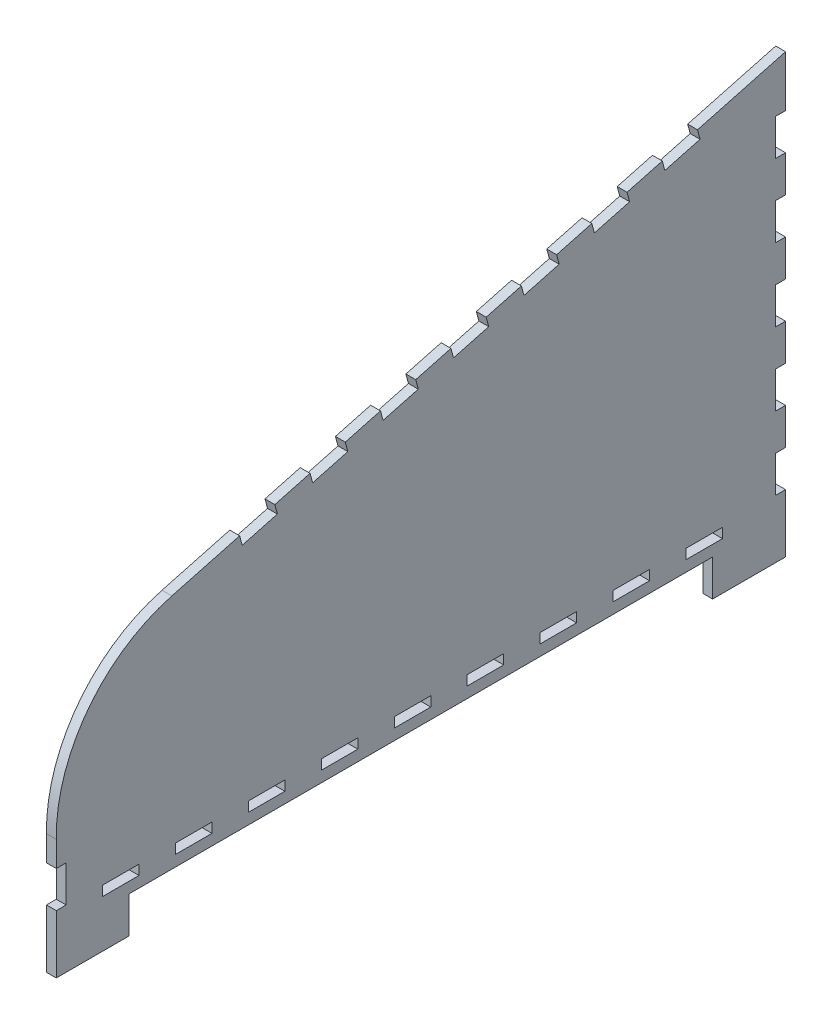
from build123d import *

# Parameters (mm, degrees)
SKETCH1_W           = 10
SKETCH1_H           = 2.7
BOSS_EXTRUDE1_DEPTH = 2.7


with BuildPart() as part:
    # Sketch1 → Boss-Extrude1 (new body)
    with BuildSketch(Plane(origin=(0, 0, 0), x_dir=(0, 0, -1), z_dir=(1, 0, 0))):
        with BuildLine():
            Line((-100, -44), (-100, -60))
            Line((-100, -60), (-80, -60))
            Line((-80, -60), (-80, -50))
            Line((-80, -50), (80, -50))
            Line((80, -50), (80, -60))
            Line((80, -60), (100, -60))
            Line((100, -60), (100, -44))
            Line((100, -44), (97.3, -44))
            Line((97.3, -44), (97.3, -34))
            Line((97.3, -34), (100, -34))
            Line((100, -34), (100, -24))
            Line((100, -24), (97.3, -24))
            Line((97.3, -24), (97.3, -14))
            Line((97.3, -14), (100, -14))
            Line((100, -14), (100, -4))
            Line((100, -4), (97.3, -4))
            Line((97.3, -4), (97.3, 6))
            Line((97.3, 6), (100, 6))
            Line((100, 6), (100, 16))
            Line((100, 16), (97.3, 16))
            Line((97.3, 16), (97.3, 26))
            Line((97.3, 26), (100, 26))
            Line((100, 26), (100, 36))
            Line((100, 36), (97.3, 36))
            Line((97.3, 36), (97.3, 46))
            Line((97.3, 46), (100, 46))
            Line((100, 46), (100, 60))
            Line((100, 60), (75.851854343, 53.529523872))
            Line((75.851854343, 53.529523872), (76.550665765, 50.921524141))
            Line((76.550665765, 50.921524141), (66.891407502, 48.33333369))
            Line((66.891407502, 48.33333369), (66.19259608, 50.941333421))
            Line((66.19259608, 50.941333421), (56.533337817, 48.35314297))
            Line((56.533337817, 48.35314297), (57.232149239, 45.745143239))
            Line((57.232149239, 45.745143239), (47.572890976, 43.156952788))
            Line((47.572890976, 43.156952788), (46.874079554, 45.764952519))
            Line((46.874079554, 45.764952519), (37.214821291, 43.176762068))
            Line((37.214821291, 43.176762068), (37.913632713, 40.568762337))
            Line((37.913632713, 40.568762337), (28.25437445, 37.980571886))
            Line((28.25437445, 37.980571886), (27.555563028, 40.588571617))
            Line((27.555563028, 40.588571617), (17.896304765, 38.000381166))
            Line((17.896304765, 38.000381166), (18.595116187, 35.392381435))
            Line((18.595116187, 35.392381435), (8.935857924, 32.804190984))
            Line((8.935857924, 32.804190984), (8.237046503, 35.412190715))
            Line((8.237046503, 35.412190715), (-1.42221176, 32.824000264))
            Line((-1.42221176, 32.824000264), (-0.723400339, 30.216000533))
            Line((-0.723400339, 30.216000533), (-10.382658601, 27.627810082))
            Line((-10.382658601, 27.627810082), (-11.081470023, 30.235809813))
            Line((-11.081470023, 30.235809813), (-20.740728286, 27.647619362))
            Line((-20.740728286, 27.647619362), (-20.041916864, 25.039619631))
            Line((-20.041916864, 25.039619631), (-29.701175127, 22.45142918))
            Line((-29.701175127, 22.45142918), (-30.399986549, 25.059428911))
            Line((-30.399986549, 25.059428911), (-40.059244812, 22.47123846))
            Line((-40.059244812, 22.47123846), (-39.36043339, 19.863238729))
            Line((-39.36043339, 19.863238729), (-49.019691653, 17.275048278))
            Line((-49.019691653, 17.275048278), (-49.718503075, 19.883048009))
            Line((-49.718503075, 19.883048009), (-68.302221487, 14.903555668))
            ThreePointArc((-68.302221487, 14.903555668), (-91.366544651, -0.636913735), (-100, -27.074247963))
            Line((-100, -27.074247963), (-100, -34))
            Line((-100, -34), (-97.3, -34))
            Line((-97.3, -34), (-97.3, -44))
            Line((-97.3, -44), (-100, -44))
        make_face()
        with Locations((-82.3, -45.65)):
            Rectangle(SKETCH1_W, SKETCH1_H, mode=Mode.SUBTRACT)
        with Locations((-62.3, -45.65)):
            Rectangle(SKETCH1_W, SKETCH1_H, mode=Mode.SUBTRACT)
        with Locations((-42.3, -45.65)):
            Rectangle(SKETCH1_W, SKETCH1_H, mode=Mode.SUBTRACT)
        with Locations((-22.3, -45.65)):
            Rectangle(SKETCH1_W, SKETCH1_H, mode=Mode.SUBTRACT)
        with Locations((-2.3, -45.65)):
            Rectangle(SKETCH1_W, SKETCH1_H, mode=Mode.SUBTRACT)
        with Locations((17.7, -45.65)):
            Rectangle(SKETCH1_W, SKETCH1_H, mode=Mode.SUBTRACT)
        with Locations((37.7, -45.65)):
            Rectangle(SKETCH1_W, SKETCH1_H, mode=Mode.SUBTRACT)
        with Locations((57.7, -45.65)):
            Rectangle(SKETCH1_W, SKETCH1_H, mode=Mode.SUBTRACT)
        with Locations((77.7, -45.65)):
            Rectangle(SKETCH1_W, SKETCH1_H, mode=Mode.SUBTRACT)
    extrude(amount=BOSS_EXTRUDE1_DEPTH)


solid = part.part
